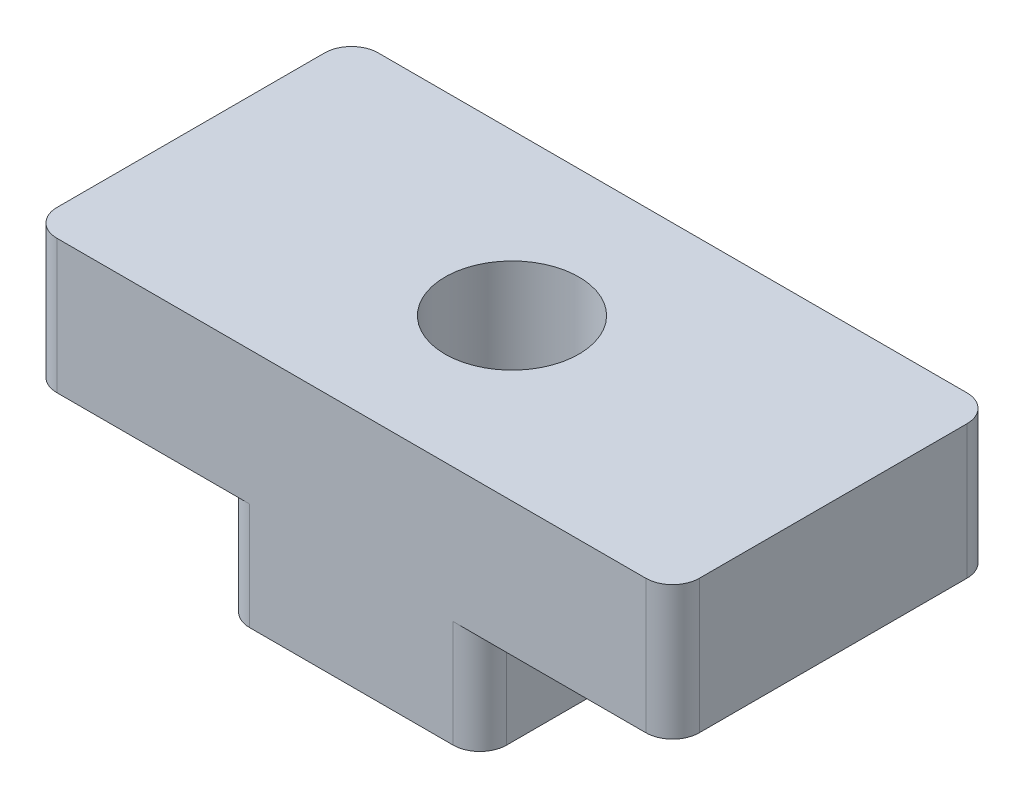
from build123d import *

# Parameters (mm, degrees)
BOSS_EXTRU_1_DEPTH      = 3
ESQUISSE2_R             = 1.25
ENL_V_MAT_EXTRU_1_DEPTH = 5.5
CONG_1_R                = 0.5


with BuildPart() as part:
    # Esquisse1 → Boss.-Extru.1 (new body, symmetric)
    with BuildSketch(Plane.XY):
        Polygon((-6, 0), (-2.4, 0), (-2.4, -2), (2.4, -2), (2.4, 0), (6, 0), (6, 2.5), (-6, 2.5), align=None)
    extrude(amount=BOSS_EXTRU_1_DEPTH, both=True)

    # Esquisse2 → Enlèv. mat.-Extru.1 (cut, through all)
    with BuildSketch(Plane(origin=(0, 2.5, 0), x_dir=(1, 0, 0), z_dir=(0, 1, 0))):
        Circle(ESQUISSE2_R)
    extrude(amount=-ENL_V_MAT_EXTRU_1_DEPTH, mode=Mode.SUBTRACT)

    # Congé1
    cong_1_edges = [part.edges().sort_by_distance(p)[0] for p in [
        (-6, 1.25, -3),
        (6, 1.25, -3),
        (-6, 1.25, 3),
        (-2.4, -1, 3),
        (2.4, -1, 3),
        (6, 1.25, 3),
        (2.4, -1, -3),
        (-2.4, -1, -3),
    ]]
    fillet(cong_1_edges, radius=CONG_1_R)


solid = part.part
